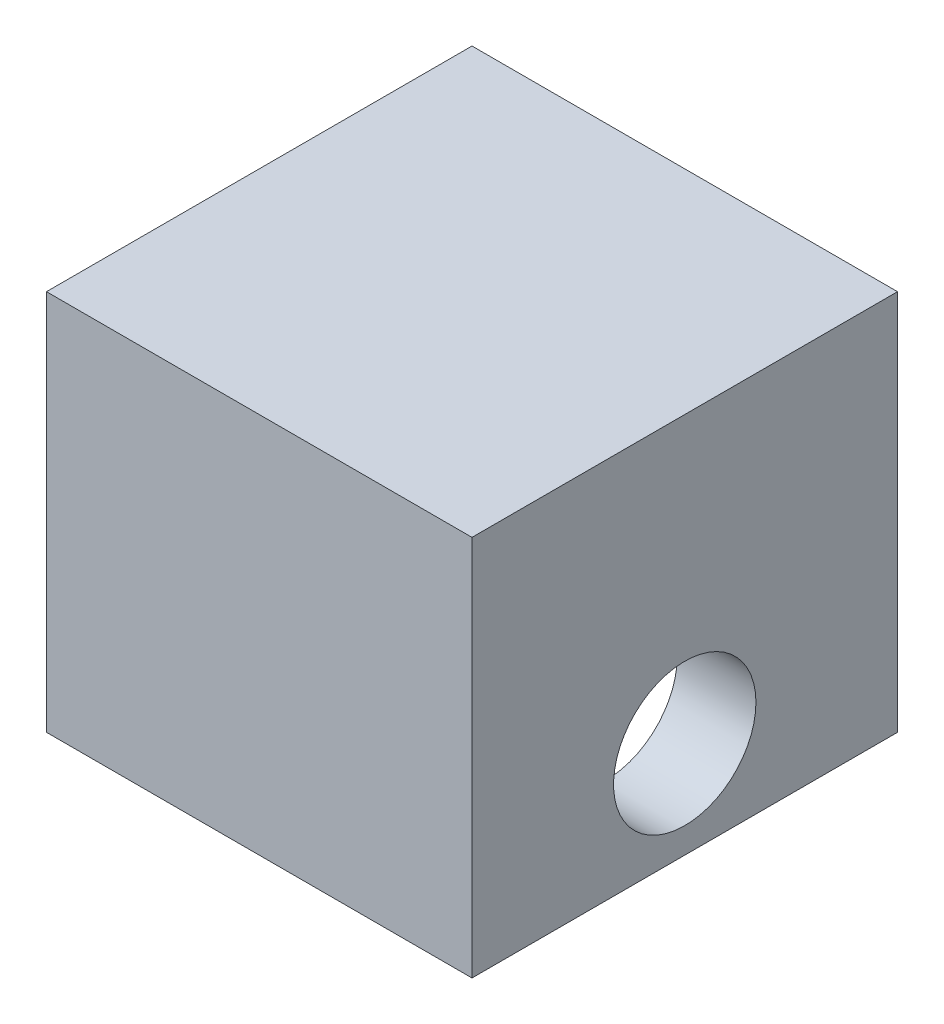
from build123d import *

# Parameters (mm, degrees)
BOSS_EXTRUDE1_DEPTH = 10.795
SKETCH2_R           = 2.12471
CUT_EXTRUDE1_DEPTH  = 13.7
SKETCH3_W           = 10.795
SKETCH3_H           = 0.6985
CUT_EXTRUDE2_DEPTH  = 13.7
SKETCH4_W           = 0.9525
SKETCH4_H           = 11.38936
BOSS_EXTRUDE2_DEPTH = 12.7


with BuildPart() as part:
    # Sketch1 → Boss-Extrude1 (new body)
    with BuildSketch(Plane.XY):
        Polygon((0, 0), (0, 10.08888), (8.001, 10.08888), (8.001, 0), (10.3505, 0), (10.3505, 12.08786), (-2.3495, 12.08786), (-2.3495, 0), align=None)
    extrude(amount=BOSS_EXTRUDE1_DEPTH)

    # Sketch2 → Cut-Extrude1 (cut, through all)
    with BuildSketch(Plane(origin=(10.3505, 0, 0), x_dir=(0, 0, -1), z_dir=(1, 0, 0))):
        with Locations((-5.3975, 3.58648)):
            Circle(SKETCH2_R)
    extrude(amount=-CUT_EXTRUDE1_DEPTH, mode=Mode.SUBTRACT)

    # Sketch3 → Cut-Extrude2 (cut, through all)
    with BuildSketch(Plane(origin=(10.3505, 0, 0), x_dir=(0, 0, -1), z_dir=(1, 0, 0))):
        with Locations((-5.3975, 0.34925)):
            Rectangle(SKETCH3_W, SKETCH3_H)
    extrude(amount=-CUT_EXTRUDE2_DEPTH, mode=Mode.SUBTRACT)

    # Sketch4 → Boss-Extrude2 (add)
    with BuildSketch(Plane(origin=(10.3505, 0, 0), x_dir=(0, 0, -1), z_dir=(1, 0, 0))):
        with Locations((-11.27125, 6.39318)):
            Rectangle(SKETCH4_W, SKETCH4_H)
        with Locations((0.47625, 6.39318)):
            Rectangle(SKETCH4_W, SKETCH4_H)
    extrude(amount=-BOSS_EXTRUDE2_DEPTH)


solid = part.part
